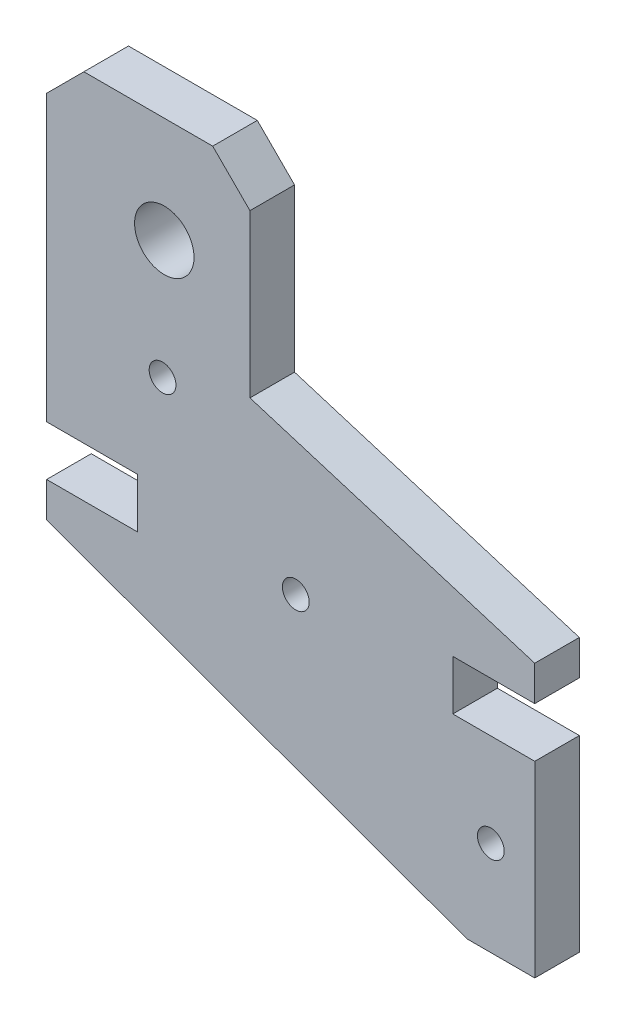
from build123d import *

# Parameters (mm, degrees)
MODEL_R                  = 1.8
MODEL_R_2                = 4
RESSALTO_EXTRUS_O1_DEPTH = 6


with BuildPart() as part:
    # Model → Ressalto-extrusão1 (new body)
    with BuildSketch(Plane.XY):
        Polygon((39.338603549, 33.894434028), (39.338603549, 40.60903008), (27.115699134, 40.60903008), (27.115699127, 78.895034597), (32.12692686, 83.90626233), (49.461276894, 83.906262358), (54.472504627, 78.895034645), (54.472504634, 57.076803542), (92.787264171, 45.319808703), (92.787264171, 40.60903008), (81.764808786, 40.60903008), (81.764808786, 33.894434028), (92.79400105, 33.894434035), (92.79400105, 8.643266236), (83.673566577, 8.643266228), (27.115699134, 29.183655407), (27.115699134, 33.894434028), align=None)
        with Locations((86.880751581, 21.371784671)):
            Circle(MODEL_R, mode=Mode.SUBTRACT)
        with Locations((60.638601845, 37.251732042)):
            Circle(MODEL_R, mode=Mode.SUBTRACT)
        with Locations((42.712190227, 53.576442757)):
            Circle(MODEL_R, mode=Mode.SUBTRACT)
        with Locations((42.946680849, 69.67437556)):
            Circle(MODEL_R_2, mode=Mode.SUBTRACT)
    extrude(amount=RESSALTO_EXTRUS_O1_DEPTH)


solid = part.part
